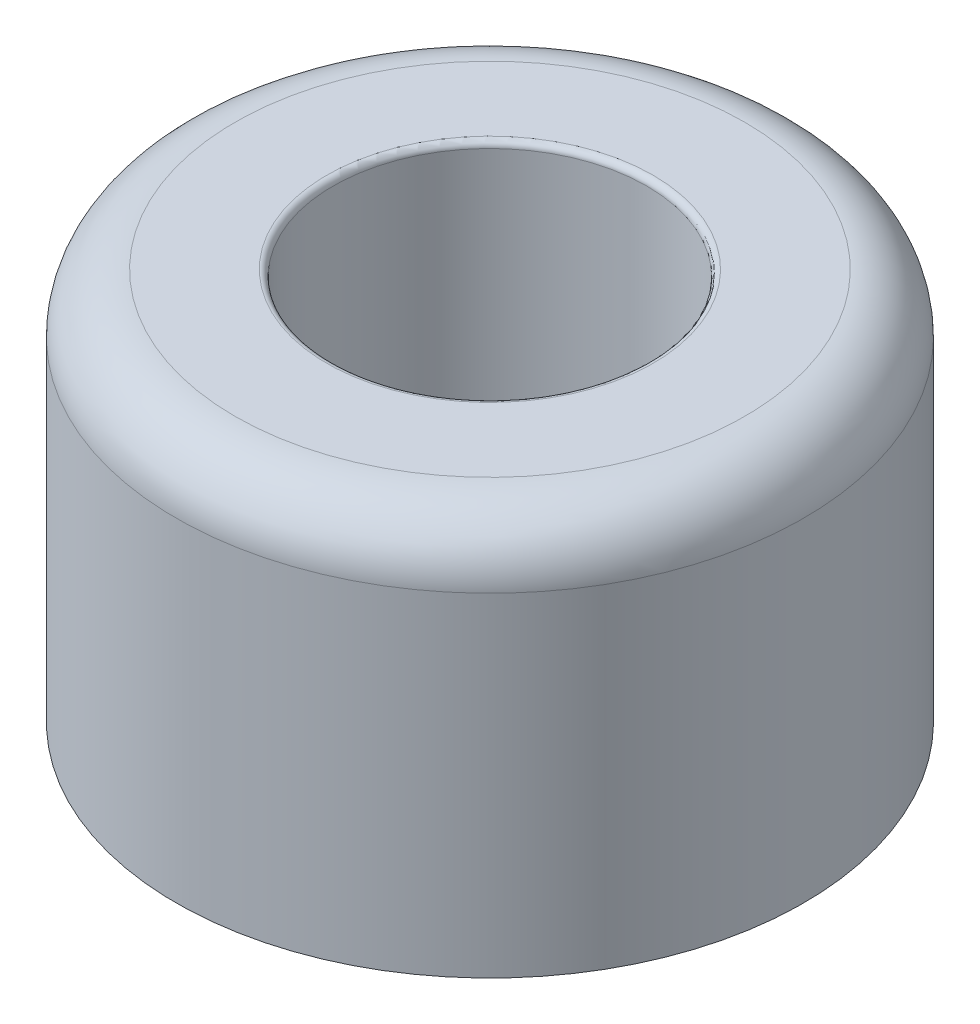
from build123d import *

# Parameters (mm, degrees)
FILLET1_R = 0.127


with BuildPart() as part:
    # Sketch2 → Revolve1 (revolve)
    with BuildSketch(Plane.XY):
        with BuildLine():
            Line((-6.35, 0), (-6.35, 6.746875))
            ThreePointArc((-6.35, 6.746875), (-6.001274011, 7.588774011), (-5.159375, 7.9375))
            Line((-5.159375, 7.9375), (-3.175, 7.9375))
            Line((-3.175, 7.9375), (-3.175, 3.175))
            Line((-3.175, 3.175), (-1.984375, 3.175))
            Line((-1.984375, 3.175), (-1.984375, 0))
            Line((-1.984375, 0), (-6.35, 0))
        make_face()
    revolve(axis=Axis((0, 0, 0), (0, 1, 0)))

    # Fillet1
    fillet1_edges = [part.edges().sort_by_distance(p)[0] for p in [
        (3.175, 7.9375, 0),
    ]]
    fillet(fillet1_edges, radius=FILLET1_R)


solid = part.part
